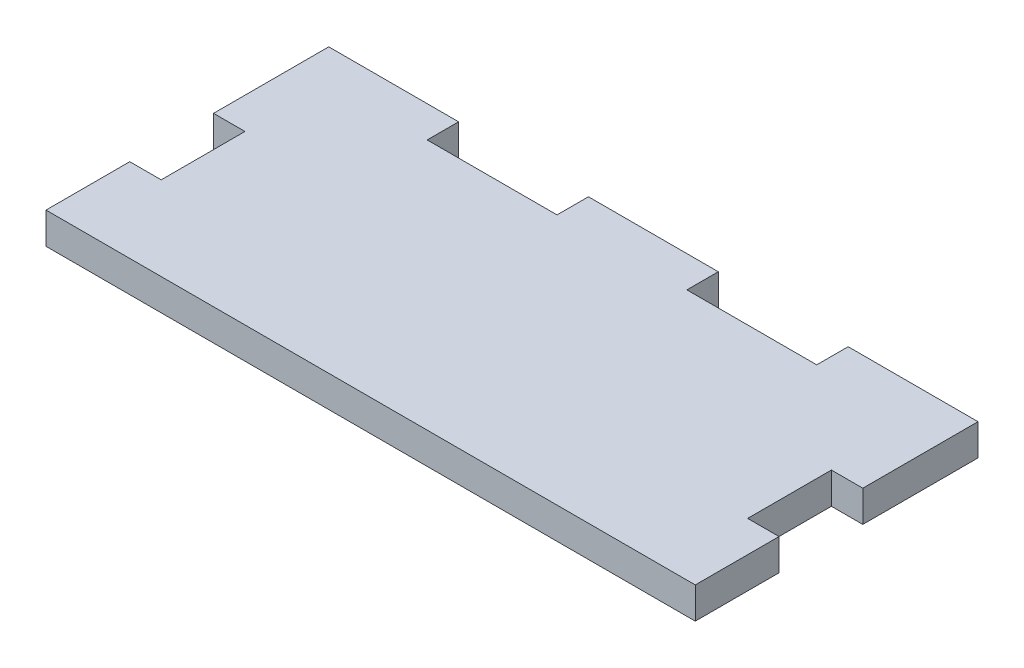
from build123d import *

# Parameters (mm, degrees)
BOSS_EXTRUDE1_DEPTH = 3


with BuildPart() as part:
    # Sketch1 → Boss-Extrude1 (new body)
    with BuildSketch(Plane(origin=(0, 0, 0), x_dir=(1, 0, 0), z_dir=(0, 1, 0))):
        Polygon((28, 2.5), (31, 2.5), (31, 13.5), (18.6, 13.5), (18.6, 10.5), (6.2, 10.5), (6.2, 13.5), (-6.2, 13.5), (-6.2, 10.5), (-18.6, 10.5), (-18.6, 13.5), (-31, 13.5), (-31, 2.5), (-28, 2.5), (-28, -5.5), (-31, -5.5), (-31, -13.5), (31, -13.5), (31, -5.5), (28, -5.5), align=None)
    extrude(amount=BOSS_EXTRUDE1_DEPTH)


solid = part.part
